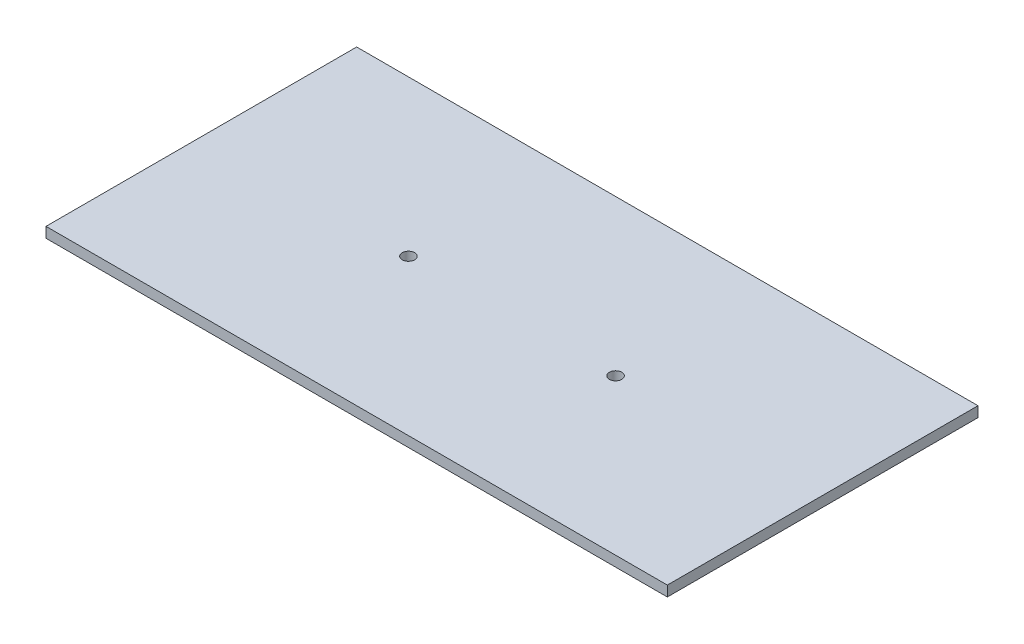
from build123d import *

# Parameters (mm, degrees)
SKETCH1_W           = 300
SKETCH1_H           = 150
BOSS_EXTRUDE1_DEPTH = 5
CUT_EXTRUDE1_REACH  = 7
SKETCH2_R           = 3


with BuildPart() as part:
    # Sketch1 → Boss-Extrude1 (new body)
    with BuildSketch(Plane(origin=(0, 0, 0), x_dir=(1, 0, 0), z_dir=(0, 1, 0))):
        Rectangle(SKETCH1_W, SKETCH1_H)
    extrude(amount=BOSS_EXTRUDE1_DEPTH)

    # Sketch2 → Cut-Extrude1 (cut, up to next)
    with BuildSketch(Plane(origin=(0, 5, 0), x_dir=(1, 0, 0), z_dir=(0, 1, 0)), mode=Mode.PRIVATE) as cut_extrude1_sk1:
        with Locations((-50, 0)):
            Circle(SKETCH2_R)
    cut_extrude1_tool1 = extrude(cut_extrude1_sk1.sketch, amount=-CUT_EXTRUDE1_REACH, mode=Mode.PRIVATE) & part.part
    add(cut_extrude1_tool1.solids().sort_by_distance((-50, 5, 0))[0], mode=Mode.SUBTRACT)
    # Sketch2 → Cut-Extrude1 (cut, up to next)
    with BuildSketch(Plane(origin=(0, 5, 0), x_dir=(1, 0, 0), z_dir=(0, 1, 0)), mode=Mode.PRIVATE) as cut_extrude1_sk2:
        with Locations((50, 0)):
            Circle(SKETCH2_R)
    cut_extrude1_tool2 = extrude(cut_extrude1_sk2.sketch, amount=-CUT_EXTRUDE1_REACH, mode=Mode.PRIVATE) & part.part
    add(cut_extrude1_tool2.solids().sort_by_distance((50, 5, 0))[0], mode=Mode.SUBTRACT)


solid = part.part
